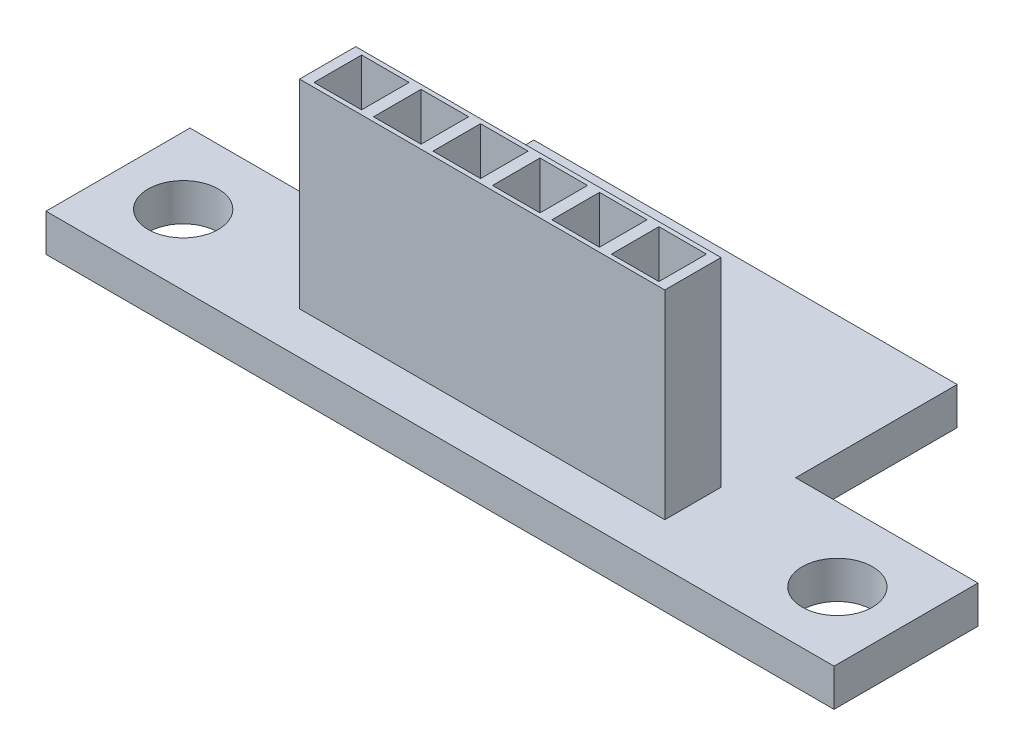
from build123d import *

# Parameters (mm, degrees)
SKETCH1_W           = 33.657442538
SKETCH1_H           = 13.047800822
BOSS_EXTRUDE1_DEPTH = 1.6
SKETCH2_W           = 15.6
SKETCH2_H           = 2.4
BOSS_EXTRUDE2_DEPTH = 8.5
SKETCH2_3_R         = 1.5
CUT_EXTRUDE2_DEPTH  = 20.950366817
SKETCH3_W           = 2.030267254
SKETCH3_H           = 2.030267255
CUT_EXTRUDE1_DEPTH  = 8
SKETCH4_W           = 7.788757613
SKETCH4_H           = 6.899262224
CUT_EXTRUDE3_DEPTH  = 20.950366817


with BuildPart() as part:
    # Sketch1 → Boss-Extrude1 (new body)
    with BuildSketch(Plane(origin=(0, 0, 0), x_dir=(1, 0, 0), z_dir=(0, 1, 0))):
        Rectangle(SKETCH1_W, SKETCH1_H)
    extrude(amount=BOSS_EXTRUDE1_DEPTH)

    # Sketch2_3 → Cut-Extrude2 (cut, through all)
    with BuildSketch(Plane(origin=(0, 1.6, 0), x_dir=(1, 0, 0), z_dir=(0, 1, 0))):
        with Locations((-13.97, -3.523900411)):
            Circle(SKETCH2_3_R)
        with Locations((13.97, -3.523900411)):
            Circle(SKETCH2_3_R)
    extrude(amount=-CUT_EXTRUDE2_DEPTH, mode=Mode.SUBTRACT)

    # Sketch4 → Cut-Extrude3 (cut, through all)
    with BuildSketch(Plane(origin=(0, 1.6, 0), x_dir=(1, 0, 0), z_dir=(0, 1, 0))):
        with Locations((-12.934342463, 3.074269299)):
            Rectangle(SKETCH4_W, SKETCH4_H)
        with Locations((12.934342463, 3.074269299)):
            Rectangle(SKETCH4_W, SKETCH4_H)
    extrude(amount=-CUT_EXTRUDE3_DEPTH, mode=Mode.SUBTRACT)


with BuildPart() as body_2:
    # Sketch2 → Boss-Extrude2 (new body)
    with BuildSketch(Plane(origin=(0, 1.6, 0), x_dir=(1, 0, 0), z_dir=(0, 1, 0))):
        with Locations((0, -3.523900411)):
            Rectangle(SKETCH2_W, SKETCH2_H)
    extrude(amount=BOSS_EXTRUDE2_DEPTH)

    # Sketch3 → Cut-Extrude1 (cut)
    with BuildSketch(Plane(origin=(0, 10.1, 0), x_dir=(1, 0, 0), z_dir=(0, 1, 0))):
        with Locations((-3.81, -3.523900412)):
            Rectangle(SKETCH3_W, SKETCH3_H)
        with Locations((-6.35, -3.523900412)):
            Rectangle(SKETCH3_W, SKETCH3_H)
        with Locations((-1.27, -3.523900412)):
            Rectangle(SKETCH3_W, SKETCH3_H)
        with Locations((1.27, -3.523900412)):
            Rectangle(SKETCH3_W, SKETCH3_H)
        with Locations((3.81, -3.523900412)):
            Rectangle(SKETCH3_W, SKETCH3_H)
        with Locations((6.35, -3.523900412)):
            Rectangle(SKETCH3_W, SKETCH3_H)
    extrude(amount=-CUT_EXTRUDE1_DEPTH, mode=Mode.SUBTRACT)


solid = Compound([part.part, body_2.part])
